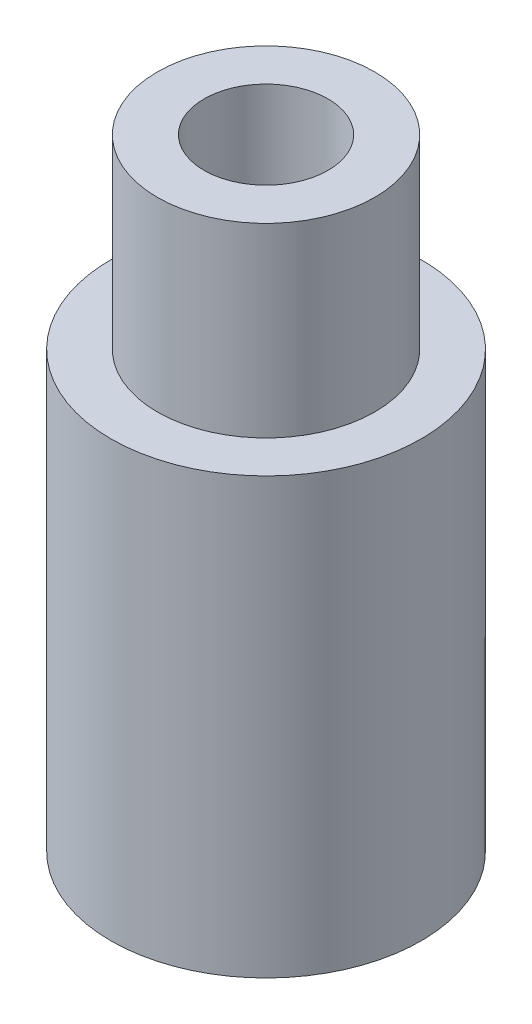
from build123d import *

# Parameters (mm, degrees)
SKETCH1_R           = 2.5019
BOSS_EXTRUDE1_DEPTH = 7.0104
SKETCH2_R           = 1.7526
BOSS_EXTRUDE2_DEPTH = 2.9972
SKETCH3_R           = 0.99949
CUT_EXTRUDE1_DEPTH  = 11.0076
SKETCH4_R           = 1.9939
CUT_EXTRUDE2_DEPTH  = 6.985


with BuildPart() as part:
    # Sketch1 → Boss-Extrude1 (new body)
    with BuildSketch(Plane(origin=(0, 0, 0), x_dir=(1, 0, 0), z_dir=(0, 1, 0))):
        Circle(SKETCH1_R)
    extrude(amount=BOSS_EXTRUDE1_DEPTH)

    # Sketch2 → Boss-Extrude2 (add)
    with BuildSketch(Plane(origin=(0, 7.0104, 0), x_dir=(1, 0, 0), z_dir=(0, 1, 0))):
        Circle(SKETCH2_R)
    extrude(amount=BOSS_EXTRUDE2_DEPTH)

    # Sketch3 → Cut-Extrude1 (cut, through all)
    with BuildSketch(Plane(origin=(0, 10.0076, 0), x_dir=(1, 0, 0), z_dir=(0, 1, 0))):
        Circle(SKETCH3_R)
    extrude(amount=-CUT_EXTRUDE1_DEPTH, mode=Mode.SUBTRACT)

    # Sketch4 → Cut-Extrude2 (cut)
    with BuildSketch(Plane.XZ):
        Circle(SKETCH4_R)
    extrude(amount=-CUT_EXTRUDE2_DEPTH, mode=Mode.SUBTRACT)


solid = part.part
